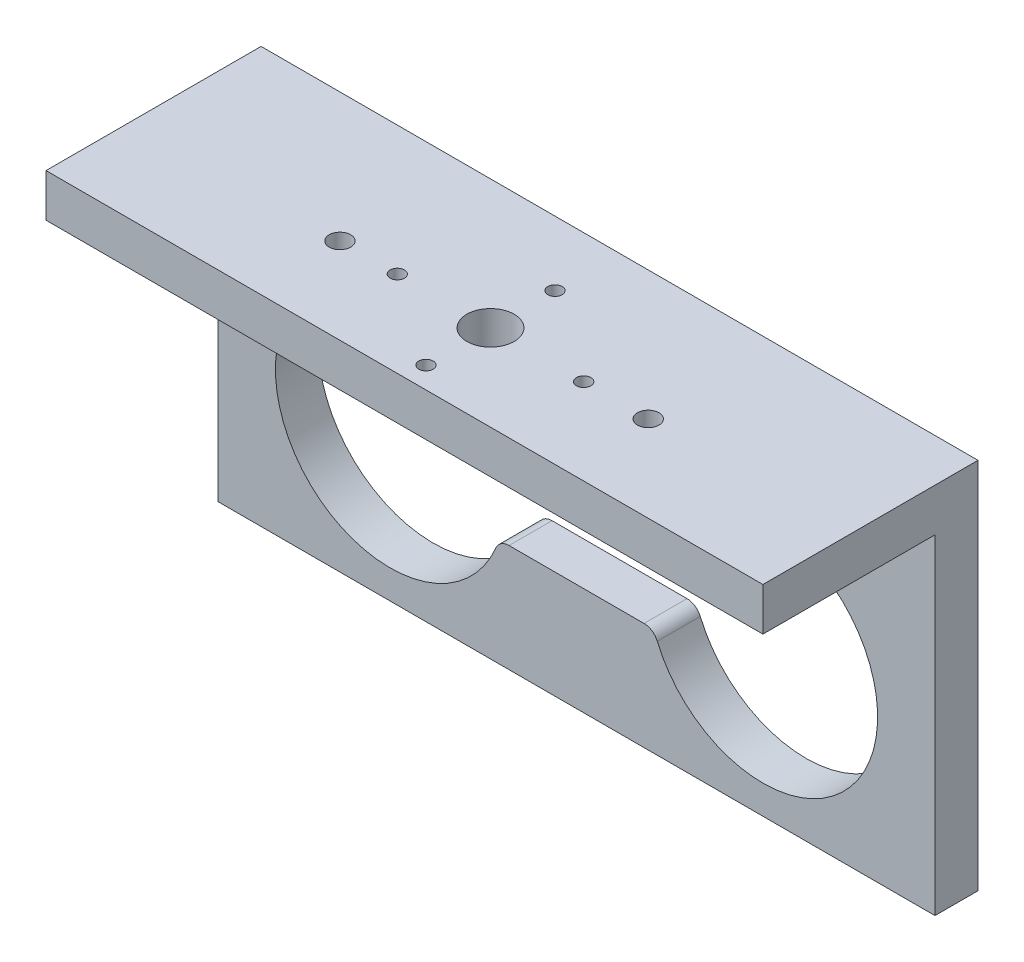
from build123d import *

# Parameters (mm, degrees)
SKETCH_1_W          = 50
SKETCH_1_H          = 20
EXTRUDE_1_DEPTH     = 3
SKETCH_2_W          = 50
SKETCH_2_H          = 15
EXTRUDE_2_DEPTH     = 6
SKETCH_5_W          = 50
SKETCH_5_H          = 12
CUT_EXTRUDE_2_DEPTH = 3
SKETCH_4_R          = 1.65
SKETCH_4_R_2        = 0.5
SKETCH_4_R_3        = 0.75
CUT_EXTRUDE_1_DEPTH = 3


with BuildPart() as part:
    # 草图1 → 凸台-拉伸1 (new body)
    with BuildSketch(Plane.XY):
        Rectangle(SKETCH_1_W, SKETCH_1_H)
        with BuildLine():
            Line((-4.708438024, 2.5), (4.708438024, 2.5))
            ThreePointArc((4.708438024, 2.5), (5.261208823, 2.666666667), (5.629722688, 3.111111111))
            ThreePointArc((5.629722688, 3.111111111), (21, 0), (5.629722688, -3.111111111))
            ThreePointArc((5.629722688, -3.111111111), (5.261208823, -2.666666667), (4.708438024, -2.5))
            Line((4.708438024, -2.5), (-4.708438024, -2.5))
            ThreePointArc((-4.708438024, -2.5), (-5.261208823, -2.666666667), (-5.629722688, -3.111111111))
            ThreePointArc((-5.629722688, -3.111111111), (-21, 0), (-5.629722688, 3.111111111))
            ThreePointArc((-5.629722688, 3.111111111), (-5.261208823, 2.666666667), (-4.708438024, 2.5))
        make_face(mode=Mode.SUBTRACT)
        with BuildLine():
            Line((3.25, 5.5), (-3.25, 5.5))
            ThreePointArc((-3.25, 5.5), (-5, 7.25), (-3.25, 9))
            Line((-3.25, 9), (3.25, 9))
            ThreePointArc((3.25, 9), (5, 7.25), (3.25, 5.5))
        make_face(mode=Mode.SUBTRACT)
    extrude(amount=EXTRUDE_1_DEPTH)

    # 草图2 → 凸台-拉伸2 (add)
    with BuildSketch(Plane(origin=(0, 10, 0), x_dir=(1, 0, 0), z_dir=(0, 1, 0))):
        with Locations((0, -7.5)):
            Rectangle(SKETCH_2_W, SKETCH_2_H)
    extrude(amount=EXTRUDE_2_DEPTH)

    # 草图5 → 切除-拉伸2 (cut)
    with BuildSketch(Plane.XZ.offset(-10)):
        with Locations((0, 9)):
            Rectangle(SKETCH_5_W, SKETCH_5_H)
    extrude(amount=-CUT_EXTRUDE_2_DEPTH, mode=Mode.SUBTRACT)

    # 草图4 → 切除-拉伸1 (cut)
    with BuildSketch(Plane(origin=(0, 16, 0), x_dir=(1, 0, 0), z_dir=(0, 1, 0))):
        with Locations((0, -9)):
            Circle(SKETCH_4_R)
        with Locations((6.5, -9)):
            Circle(SKETCH_4_R_2)
        with Locations((-6.5, -9)):
            Circle(SKETCH_4_R_2)
        with Locations((11, -9)):
            Circle(SKETCH_4_R_3)
        with Locations((-10.5, -9)):
            Circle(SKETCH_4_R_3)
        with Locations((0, -4.5)):
            Circle(SKETCH_4_R_2)
        with Locations((0, -13.5)):
            Circle(SKETCH_4_R_2)
    extrude(amount=-CUT_EXTRUDE_1_DEPTH, mode=Mode.SUBTRACT)


solid = part.part
